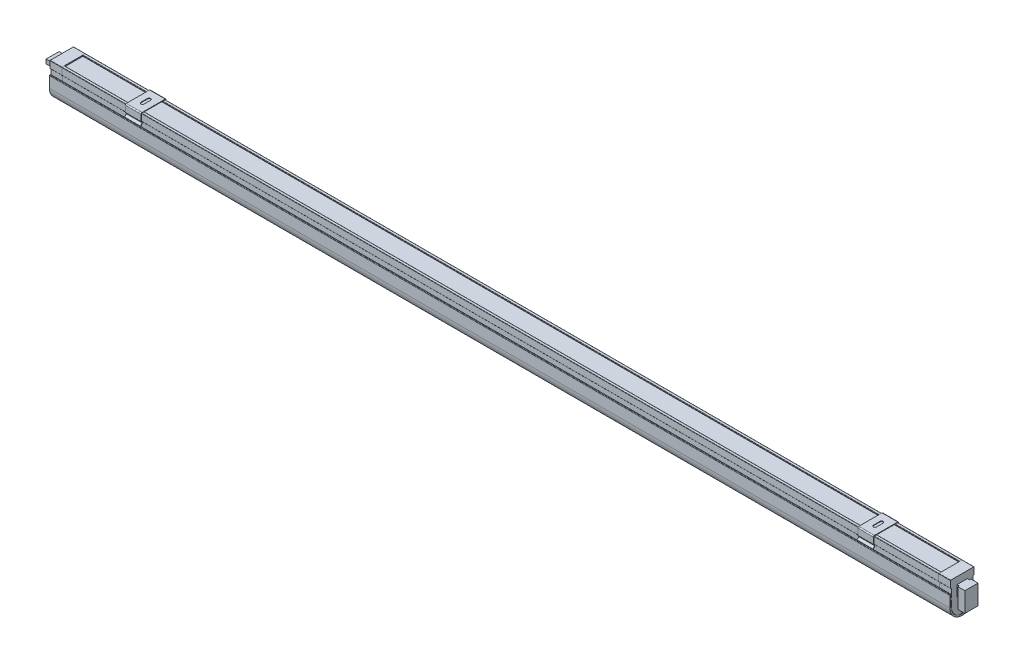
from build123d import *

# Parameters (mm, degrees)
BOSS_EXTRUDE1_DEPTH    = 848.36
BOSS_EXTRUDE2_DEPTH    = 848.36
BOSS_EXTRUDE3_DEPTH    = 11.43
CUT_EXTRUDE2_DEPTH     = 10.0076
BOSS_EXTRUDE6_REACH    = 13.43
BOSS_EXTRUDE7_DEPTH    = 6.7818
SKETCH5_4_W            = 10.16
SKETCH5_4_H            = 10.16
BOSS_EXTRUDE9_DEPTH    = 8.89
SKETCH6_W              = 12.7
SKETCH6_H              = 3.9878
BOSS_EXTRUDE10_DEPTH   = 8.89
SKETCH7_R              = 2.54
CUT_EXTRUDE3_DEPTH     = 6.096
SKETCH8_R              = 2.2606
SKETCH8_R_2            = 1.143
BOSS_EXTRUDE11_DEPTH   = 5.842
SKETCH8_2_R            = 1.143
BOSS_EXTRUDE12_DEPTH   = 13.7922
FILLET1_R              = 1.1176
BOSS_EXTRUDE13_START   = 424.18
SKETCH9_R              = 1.143
BOSS_EXTRUDE13_DEPTH   = 6.985
BOSS_EXTRUDE13_2_DEPTH = 6.985
BOSS_EXTRUDE14_START   = 424.18
SKETCH9_4_R            = 1.143
BOSS_EXTRUDE14_DEPTH   = 2.032
BOSS_EXTRUDE15_START   = 413.1818
SKETCH9_5_R            = 7.62
SKETCH9_5_R_2          = 7.3025
SKETCH9_5_R_3          = 1.143
BOSS_EXTRUDE15_DEPTH   = 8.9662
SKETCH9_6_R            = 7.9375
SKETCH9_6_R_2          = 7.62
SKETCH9_6_R_3          = 7.3025
BOSS_EXTRUDE16_DEPTH   = 413.1818
FILLET3_R              = 0.127
BOSS_EXTRUDE17_DEPTH   = 871.22
BOSS_EXTRUDE18_START   = -82.55
BOSS_EXTRUDE18_DEPTH   = 15.24
CUT_EXTRUDE4_DEPTH     = 0.508


with BuildPart() as part:
    # Sketch1 → Boss-Extrude1 (new body)
    with BuildSketch(Plane(origin=(-20.32, 0, 0), x_dir=(0, 0, -1), z_dir=(1, 0, 0))):
        with BuildLine():
            Line((2.3114, 0), (0.254, 0))
            ThreePointArc((0.254, 0), (0.074394878, -0.074394878), (0, -0.254))
            Line((0, -0.254), (0, -6.540681466))
            ThreePointArc((0, -6.540681466), (0.134713703, -6.859448936), (0.4572, -6.985))
            ThreePointArc((0.4572, -6.985), (0.779686297, -7.110551064), (0.9144, -7.429318534))
            Line((0.9144, -7.429318534), (0.9144, -14.986207389))
            ThreePointArc((0.9144, -14.986207389), (0.760441483, -15.350513069), (0.391885714, -15.494))
            ThreePointArc((0.391885714, -15.494), (0.115468888, -15.601615198), (0, -15.874844458))
            Line((0, -15.874844458), (0, -16.383362931))
            ThreePointArc((0, -16.383362931), (0.115468888, -16.656592191), (0.391885714, -16.764207389))
            ThreePointArc((0.391885714, -16.764207389), (0.760441483, -16.90769432), (0.9144, -17.272))
            ThreePointArc((0.9144, -17.272), (1.937798719, -19.036014585), (3.97714356, -19.023168671))
            ThreePointArc((3.97714356, -19.023168671), (7.567737766, -17.509328725), (11.43, -16.9926))
            ThreePointArc((11.43, -16.9926), (15.292262234, -17.509328725), (18.88285644, -19.023168671))
            ThreePointArc((18.88285644, -19.023168671), (20.922201281, -19.036014585), (21.9456, -17.272))
            ThreePointArc((21.9456, -17.272), (22.099558517, -16.90769432), (22.468114286, -16.764207389))
            ThreePointArc((22.468114286, -16.764207389), (22.744531112, -16.656592191), (22.86, -16.383362931))
            Line((22.86, -16.383362931), (22.86, -15.874844458))
            ThreePointArc((22.86, -15.874844458), (22.744531112, -15.601615198), (22.468114286, -15.494))
            ThreePointArc((22.468114286, -15.494), (22.099558517, -15.350513069), (21.9456, -14.986207389))
            Line((21.9456, -14.986207389), (21.9456, -7.429318534))
            ThreePointArc((21.9456, -7.429318534), (22.080313703, -7.110551064), (22.4028, -6.985))
            ThreePointArc((22.4028, -6.985), (22.725286297, -6.859448936), (22.86, -6.540681466))
            Line((22.86, -6.540681466), (22.86, -0.254))
            ThreePointArc((22.86, -0.254), (22.785605122, -0.074394878), (22.606, 0))
            Line((22.606, 0), (20.5486, 0))
            ThreePointArc((20.5486, 0), (20.368994878, -0.074394878), (20.2946, -0.254))
            Line((20.2946, -0.254), (20.2946, -0.762))
            ThreePointArc((20.2946, -0.762), (20.368994878, -0.941605122), (20.5486, -1.016))
            Line((20.5486, -1.016), (21.59, -1.016))
            Line((21.59, -1.016), (21.59, -1.524))
            Line((21.59, -1.524), (21.1836, -1.524))
            Line((21.1836, -1.524), (21.1836, -17.272))
            ThreePointArc((21.1836, -17.272), (20.5439758, -18.374509116), (19.269385275, -18.366480419))
            ThreePointArc((19.269385275, -18.366480419), (15.492571435, -16.77412792), (11.43, -16.2306))
            ThreePointArc((11.43, -16.2306), (7.367428565, -16.77412792), (3.590614725, -18.366480419))
            ThreePointArc((3.590614725, -18.366480419), (2.3160242, -18.374509116), (1.6764, -17.272))
            Line((1.6764, -17.272), (1.6764, -1.524))
            Line((1.6764, -1.524), (1.27, -1.524))
            Line((1.27, -1.524), (1.27, -1.016))
            Line((1.27, -1.016), (2.3114, -1.016))
            ThreePointArc((2.3114, -1.016), (2.491005122, -0.941605122), (2.5654, -0.762))
            Line((2.5654, -0.762), (2.5654, -0.254))
            ThreePointArc((2.5654, -0.254), (2.491005122, -0.074394878), (2.3114, 0))
        make_face()
    extrude(amount=-BOSS_EXTRUDE1_DEPTH)


with BuildPart() as body_2:
    # Sketch1_3 → Boss-Extrude2 (new body)
    with BuildSketch(Plane(origin=(-20.32, 0, 0), x_dir=(0, 0, -1), z_dir=(1, 0, 0))):
        Polygon((11.43, -1.524), (1.27, -1.524), (1.27, -1.016), (11.43, -1.016), (21.59, -1.016), (21.59, -1.524), align=None)
    extrude(amount=-BOSS_EXTRUDE2_DEPTH)


with BuildPart() as body_3:
    # Sketch3 → Boss-Extrude3 (new body)
    with BuildSketch(Plane(origin=(-20.32, 0, 0), x_dir=(0, 0, -1), z_dir=(1, 0, 0))):
        with BuildLine():
            Line((0, -6.540681466), (0, -0.254))
            ThreePointArc((0, -0.254), (0.074394878, -0.074394878), (0.254, 0))
            Line((0.254, 0), (22.606, 0))
            ThreePointArc((22.606, 0), (22.785605122, -0.074394878), (22.86, -0.254))
            Line((22.86, -0.254), (22.86, -6.540681466))
            ThreePointArc((22.86, -6.540681466), (22.725286297, -6.859448936), (22.4028, -6.985))
            ThreePointArc((22.4028, -6.985), (22.080313703, -7.110551064), (21.9456, -7.429318534))
            Line((21.9456, -7.429318534), (21.9456, -14.986207389))
            ThreePointArc((21.9456, -14.986207389), (22.099558517, -15.350513069), (22.468114286, -15.494))
            ThreePointArc((22.468114286, -15.494), (22.744531112, -15.601615198), (22.86, -15.874844458))
            Line((22.86, -15.874844458), (22.86, -16.383362931))
            ThreePointArc((22.86, -16.383362931), (22.744531112, -16.656592191), (22.468114286, -16.764207389))
            ThreePointArc((22.468114286, -16.764207389), (22.099558517, -16.90769432), (21.9456, -17.272))
            Line((21.9456, -17.272), (21.9456, -23.0124))
            ThreePointArc((21.9456, -23.0124), (19.407197451, -29.863835191), (13.0175, -33.407479947))
            Line((13.0175, -33.407479947), (13.0175, -33.02))
            Line((13.0175, -33.02), (9.8425, -33.02))
            Line((9.8425, -33.02), (9.8425, -33.407479947))
            ThreePointArc((9.8425, -33.407479947), (3.452802549, -29.863835191), (0.9144, -23.0124))
            Line((0.9144, -23.0124), (0.9144, -17.272))
            ThreePointArc((0.9144, -17.272), (0.760441483, -16.90769432), (0.391885714, -16.764207389))
            ThreePointArc((0.391885714, -16.764207389), (0.115468888, -16.656592191), (0, -16.383362931))
            Line((0, -16.383362931), (0, -15.874844458))
            ThreePointArc((0, -15.874844458), (0.115468888, -15.601615198), (0.391885714, -15.494))
            ThreePointArc((0.391885714, -15.494), (0.760441483, -15.350513069), (0.9144, -14.986207389))
            Line((0.9144, -14.986207389), (0.9144, -7.429318534))
            ThreePointArc((0.9144, -7.429318534), (0.779686297, -7.110551064), (0.4572, -6.985))
            ThreePointArc((0.4572, -6.985), (0.134713703, -6.859448936), (0, -6.540681466))
        make_face()
    extrude(amount=BOSS_EXTRUDE3_DEPTH)

    # Sketch4 → Cut-Extrude2 (cut)
    with BuildSketch(Plane.ZY.offset(20.32)):
        with BuildLine():
            Line((-13.0175, -32.859367617), (-13.0175, -33.02))
            Line((-13.0175, -33.02), (-9.8425, -33.02))
            Line((-9.8425, -33.02), (-9.8425, -32.859367617))
            ThreePointArc((-9.8425, -32.859367617), (-11.43, -17.1704), (-13.0175, -32.859367617))
        make_face()
    extrude(amount=-CUT_EXTRUDE2_DEPTH, mode=Mode.SUBTRACT)


with BuildPart() as body_4:

    # Sketch4_6 → Boss-Extrude6 (new, up to next)
    with BuildSketch(Plane.ZY.offset(20.32), mode=Mode.PRIVATE) as boss_extrude6_sk1:
        with BuildLine():
            Line((-9.8425, -18.7452), (-9.8425, -32.223057322))
            ThreePointArc((-9.8425, -32.223057322), (-5.732666194, -29.663229526), (-4.1275, -25.0952))
            ThreePointArc((-4.1275, -25.0952), (-5.732666194, -20.527170474), (-9.8425, -17.967342678))
            Line((-9.8425, -17.967342678), (-9.8425, -18.7452))
        make_face()
    boss_extrude6_tool1 = extrude(boss_extrude6_sk1.sketch, amount=-BOSS_EXTRUDE6_REACH, mode=Mode.PRIVATE) - body_3.part
    # Sketch4_6 → Boss-Extrude6 (new, up to next)
    with BuildSketch(Plane.ZY.offset(20.32), mode=Mode.PRIVATE) as boss_extrude6_sk2:
        with BuildLine():
            ThreePointArc((-13.0175, -17.967342678), (-18.7325, -25.0952), (-13.0175, -32.223057322))
            Line((-13.0175, -32.223057322), (-13.0175, -18.7452))
            Line((-13.0175, -18.7452), (-13.0175, -17.967342678))
        make_face()
    boss_extrude6_tool2 = extrude(boss_extrude6_sk2.sketch, amount=-BOSS_EXTRUDE6_REACH, mode=Mode.PRIVATE) - body_3.part
    # Sketch4_6 → Boss-Extrude6 (new, up to next)
    with BuildSketch(Plane.ZY.offset(20.32), mode=Mode.PRIVATE) as boss_extrude6_sk3:
        with BuildLine():
            Line((-13.0175, -17.967342678), (-13.0175, -18.7452))
            ThreePointArc((-13.0175, -18.7452), (-11.43, -18.549695074), (-9.8425, -18.7452))
            Line((-9.8425, -18.7452), (-9.8425, -17.967342678))
            ThreePointArc((-9.8425, -17.967342678), (-11.43, -17.7927), (-13.0175, -17.967342678))
        make_face()
    boss_extrude6_tool3 = extrude(boss_extrude6_sk3.sketch, amount=-BOSS_EXTRUDE6_REACH, mode=Mode.PRIVATE) - body_3.part
    add(boss_extrude6_tool1.solids().sort_by_distance((-20.32, -25.0952, -7.456782))[0])
    add(boss_extrude6_tool2.solids().sort_by_distance((-20.32, -25.0952, -15.403218))[0])
    add(boss_extrude6_tool3.solids().sort_by_distance((-20.32, -18.232997, -11.43))[0])


with BuildPart() as body_5:
    # Mirror1: mirrored copy
    add(body_3.part.mirror(Plane(origin=(-444.5, 0, 0), x_dir=(0, 0, 1), z_dir=(1, 0, 0))))


with BuildPart() as body_6:
    # Mirror1 2: mirrored copy
    add(body_4.part.mirror(Plane(origin=(-444.5, 0, 0), x_dir=(0, 0, 1), z_dir=(1, 0, 0))))


with BuildPart() as body_7:
    # Sketch5 → Boss-Extrude7 (new body)
    with BuildSketch(Plane(origin=(0, 0, 0), x_dir=(0, 0, -1), z_dir=(1, 0, 0))):
        Polygon((6.35, -6.7818), (5.08, -6.7818), (5.08, -25.8318), (17.78, -25.8318), (17.78, -6.7818), (16.51, -6.7818), (16.51, -16.9418), (6.35, -16.9418), align=None)
    extrude(amount=-BOSS_EXTRUDE7_DEPTH)

    # Sketch5_4 → Boss-Extrude9 (add)
    with BuildSketch(Plane(origin=(0, 0, 0), x_dir=(0, 0, -1), z_dir=(1, 0, 0))):
        with Locations((11.43, -11.8618)):
            Rectangle(SKETCH5_4_W, SKETCH5_4_H)
    extrude(amount=-BOSS_EXTRUDE9_DEPTH)

    # Sketch7 → Cut-Extrude3 (cut)
    with BuildSketch(Plane.XZ.offset(25.8318)):
        with Locations(Location((-3.3909, -8.509, 0), (0, 0, 270))):
            Circle(SKETCH7_R)
        with Locations(Location((-3.3909, -14.351, 0), (0, 0, 270))):
            Circle(SKETCH7_R)
    extrude(amount=-CUT_EXTRUDE3_DEPTH, mode=Mode.SUBTRACT)


with BuildPart() as body_8:
    # Sketch6 → Boss-Extrude10 (new body)
    with BuildSketch(Plane(origin=(-889, 0, 0), x_dir=(0, 0, -1), z_dir=(1, 0, 0))):
        with Locations((11.43, -7.8867)):
            Rectangle(SKETCH6_W, SKETCH6_H)
    extrude(amount=BOSS_EXTRUDE10_DEPTH)

    # Sketch8 → Boss-Extrude11 (add)
    with BuildSketch(Plane.XZ.offset(9.8806)):
        with Locations(Location((-884.555, -8.4836, 0), (0, 0, 90))):
            Circle(SKETCH8_R)
        with Locations(Location((-884.555, -8.4836, 0), (0, 0, 270))):
            Circle(SKETCH8_R_2, mode=Mode.SUBTRACT)
        with Locations(Location((-884.555, -14.3764, 0), (0, 0, 90))):
            Circle(SKETCH8_R)
        with Locations(Location((-884.555, -14.3764, 0), (0, 0, 270))):
            Circle(SKETCH8_R_2, mode=Mode.SUBTRACT)
    extrude(amount=BOSS_EXTRUDE11_DEPTH)

    # Sketch8_2 → Boss-Extrude12 (add)
    with BuildSketch(Plane.XZ.offset(9.8806)):
        with Locations(Location((-884.555, -8.4836, 0), (0, 0, 90))):
            Circle(SKETCH8_2_R)
        with Locations(Location((-884.555, -14.3764, 0), (0, 0, 90))):
            Circle(SKETCH8_2_R)
    extrude(amount=BOSS_EXTRUDE12_DEPTH)

    # Fillet1
    fillet1_edges = [body_8.edges().sort_by_distance(p)[0] for p in [
        (-884.555, -23.6728, -9.6266),
        (-884.555, -23.6728, -15.5194),
    ]]
    fillet(fillet1_edges, radius=FILLET1_R)


with BuildPart() as body_9:
    # Sketch9 → Boss-Extrude13 (new body)
    with BuildSketch(Plane(origin=(-444.5, 0, 0), x_dir=(0, 0, -1), z_dir=(1, 0, 0)).offset(BOSS_EXTRUDE13_START)):
        with Locations((11.43, -22.717797537)):
            Circle(SKETCH9_R)
    extrude(amount=BOSS_EXTRUDE13_DEPTH)



with BuildPart() as body_10:
    # Sketch9 → Boss-Extrude13 2 (new body)
    with BuildSketch(Plane(origin=(-444.5, 0, 0), x_dir=(0, 0, -1), z_dir=(1, 0, 0)).offset(BOSS_EXTRUDE13_START)):
        with Locations((11.43, -27.467597537)):
            Circle(SKETCH9_R)
    extrude(amount=BOSS_EXTRUDE13_2_DEPTH)


with BuildPart() as body_9_1:
    add(body_9.part)

    add(body_10.part)  # Boss-Extrude14 merges body 10
    # Sketch9_4 → Boss-Extrude14 (add)
    with BuildSketch(Plane(origin=(-444.5, 0, 0), x_dir=(0, 0, -1), z_dir=(1, 0, 0)).offset(BOSS_EXTRUDE14_START)):
        with BuildLine():
            ThreePointArc((16.8656, -20.21614559), (11.43, -17.790197537), (5.9944, -20.21614559))
            Line((5.9944, -20.21614559), (5.9944, -29.969249484))
            ThreePointArc((5.9944, -29.969249484), (11.43, -32.395197537), (16.8656, -29.969249484))
            Line((16.8656, -29.969249484), (16.8656, -20.21614559))
        make_face()
        with Locations((11.43, -27.467597537)):
            Circle(SKETCH9_4_R, mode=Mode.SUBTRACT)
        with Locations((11.43, -22.717797537)):
            Circle(SKETCH9_4_R, mode=Mode.SUBTRACT)
        with Locations((11.43, -22.717797537)):
            Circle(SKETCH9_4_R)
        with Locations((11.43, -27.467597537)):
            Circle(SKETCH9_4_R)
    extrude(amount=-BOSS_EXTRUDE14_DEPTH)

    # Sketch9_5 → Boss-Extrude15 (add)
    with BuildSketch(Plane(origin=(-444.5, 0, 0), x_dir=(0, 0, -1), z_dir=(1, 0, 0)).offset(BOSS_EXTRUDE15_START)):
        with Locations((11.43, -25.092697537)):
            Circle(SKETCH9_5_R)
        with Locations((11.43, -25.092697537)):
            Circle(SKETCH9_5_R_2, mode=Mode.SUBTRACT)
        with BuildLine():
            Line((5.9944, -29.969249484), (5.9944, -20.21614559))
            ThreePointArc((5.9944, -20.21614559), (4.1275, -25.092697537), (5.9944, -29.969249484))
        make_face()
        with BuildLine():
            ThreePointArc((16.8656, -20.21614559), (11.43, -17.790197537), (5.9944, -20.21614559))
            Line((5.9944, -20.21614559), (5.9944, -29.969249484))
            ThreePointArc((5.9944, -29.969249484), (11.43, -32.395197537), (16.8656, -29.969249484))
            Line((16.8656, -29.969249484), (16.8656, -20.21614559))
        make_face()
        with Locations((11.43, -27.467597537)):
            Circle(SKETCH9_5_R_3, mode=Mode.SUBTRACT)
        with Locations((11.43, -22.717797537)):
            Circle(SKETCH9_5_R_3, mode=Mode.SUBTRACT)
        with Locations((11.43, -22.717797537)):
            Circle(SKETCH9_5_R_3)
        with Locations((11.43, -27.467597537)):
            Circle(SKETCH9_5_R_3)
        with BuildLine():
            ThreePointArc((18.7325, -25.092697537), (18.249823137, -22.481851194), (16.8656, -20.21614559))
            Line((16.8656, -20.21614559), (16.8656, -29.969249484))
            ThreePointArc((16.8656, -29.969249484), (18.249823137, -27.70354388), (18.7325, -25.092697537))
        make_face()
    extrude(amount=BOSS_EXTRUDE15_DEPTH)

    # Sketch9_6 → Boss-Extrude16 (add)
    with BuildSketch(Plane(origin=(-444.5, 0, 0), x_dir=(0, 0, -1), z_dir=(1, 0, 0))):
        with Locations((11.43, -25.092697537)):
            Circle(SKETCH9_6_R)
        with Locations((11.43, -25.092697537)):
            Circle(SKETCH9_6_R_2, mode=Mode.SUBTRACT)
        with Locations((11.43, -25.092697537)):
            Circle(SKETCH9_6_R_2)
        with Locations((11.43, -25.092697537)):
            Circle(SKETCH9_6_R_3, mode=Mode.SUBTRACT)
    extrude(amount=BOSS_EXTRUDE16_DEPTH)

    # Fillet3
    fillet3_edges = [body_9_1.edges().sort_by_distance(p)[0] for p in [
        (-31.3182, -25.092697537, -3.81),
        (-31.3182, -25.092697537, -3.4925),
    ]]
    fillet(fillet3_edges, radius=FILLET3_R)

    # Mirror2: body 9 across plane


with BuildPart() as body_9_2:
    add(body_9_1.part)
    add(body_9_1.part.mirror(Plane(origin=(-444.5, 0, 0), x_dir=(0, 0, 1), z_dir=(1, 0, 0))))


with BuildPart() as body_10_2:
    # Sketch10 → Boss-Extrude17 (new body)
    with BuildSketch(Plane(origin=(-8.89, 0, 0), x_dir=(0, 0, -1), z_dir=(1, 0, 0))):
        with BuildLine():
            ThreePointArc((0.7874, -12.438237222), (0.657208964, -12.123928258), (0.3429, -11.993737222))
            Line((0.3429, -11.993737222), (-0.1651, -11.993737222))
            ThreePointArc((-0.1651, -11.993737222), (-0.479408964, -12.123928258), (-0.6096, -12.438237222))
            Line((-0.6096, -12.438237222), (-0.6096, -23.0124))
            ThreePointArc((-0.6096, -23.0124), (2.911309562, -31.566470345), (11.43, -35.172137665))
            ThreePointArc((11.43, -35.172137665), (19.948690438, -31.566470345), (23.4696, -23.0124))
            Line((23.4696, -23.0124), (23.4696, -12.438237222))
            ThreePointArc((23.4696, -12.438237222), (23.339408964, -12.123928258), (23.0251, -11.993737222))
            Line((23.0251, -11.993737222), (22.5171, -11.993737222))
            ThreePointArc((22.5171, -11.993737222), (22.202791036, -12.123928258), (22.0726, -12.438237222))
            Line((22.0726, -12.438237222), (22.0726, -14.863937222))
            ThreePointArc((22.0726, -14.863937222), (22.203857117, -15.204713982), (22.5298, -15.36939084))
            ThreePointArc((22.5298, -15.36939084), (22.855742883, -15.534067698), (22.987, -15.874844458))
            Line((22.987, -15.874844458), (22.987, -16.36241244))
            ThreePointArc((22.987, -16.36241244), (22.855742883, -16.7031892), (22.5298, -16.867866058))
            ThreePointArc((22.5298, -16.867866058), (22.203857117, -17.032542916), (22.0726, -17.373319676))
            Line((22.0726, -17.373319676), (22.0726, -23.0124))
            ThreePointArc((22.0726, -23.0124), (21.949624429, -23.21849213), (22.064254778, -23.429340038))
            ThreePointArc((22.064254778, -23.429340038), (22.064111918, -23.432950945), (22.063967846, -23.436561803))
            ThreePointArc((22.063967846, -23.436561803), (21.933255244, -23.637507313), (22.039233102, -23.852527256))
            ThreePointArc((22.039233102, -23.852527256), (22.038935889, -23.856285642), (22.038637359, -23.860043924))
            ThreePointArc((22.038637359, -23.860043924), (21.900401415, -24.055553365), (21.997577296, -24.274391128))
            ThreePointArc((21.997577296, -24.274391128), (21.997113921, -24.278290188), (21.996649124, -24.282189079))
            ThreePointArc((21.996649124, -24.282189079), (21.851113862, -24.471982008), (21.939353124, -24.694278435))
            ThreePointArc((21.939353124, -24.694278435), (21.938712126, -24.69831042), (21.938069599, -24.702342162))
            ThreePointArc((21.938069599, -24.702342162), (21.785468988, -24.886147469), (21.864651967, -25.111539114))
            ThreePointArc((21.864651967, -25.111539114), (21.863822304, -25.11569535), (21.862991005, -25.11985126))
            ThreePointArc((21.862991005, -25.11985126), (21.703568564, -25.297407482), (21.773590665, -25.525527258))
            ThreePointArc((21.773590665, -25.525527258), (21.772561791, -25.529798173), (21.771531175, -25.534068668))
            ThreePointArc((21.771531175, -25.534068668), (21.605539568, -25.705124285), (21.666311336, -25.935602115))
            ThreePointArc((21.666311336, -25.935602115), (21.665073272, -25.939977268), (21.663833361, -25.944351897))
            ThreePointArc((21.663833361, -25.944351897), (21.491533991, -26.108665609), (21.542981144, -26.341129067))
            ThreePointArc((21.542981144, -26.341129067), (21.54152455, -26.345597185), (21.540066006, -26.350064667))
            ThreePointArc((21.540066006, -26.350064667), (21.3617286, -26.507405657), (21.403792041, -26.741480612))
            ThreePointArc((21.403792041, -26.741480612), (21.402108281, -26.746029635), (21.400422473, -26.750577899))
            ThreePointArc((21.400422473, -26.750577899), (21.216324664, -26.900726076), (21.248960456, -27.136037324))
            ThreePointArc((21.248960456, -27.136037324), (21.247041667, -27.140654451), (21.245120735, -27.145270686))
            ThreePointArc((21.245120735, -27.145270686), (21.055547642, -27.288016915), (21.078726967, -27.524188806))
            ThreePointArc((21.078726967, -27.524188806), (21.076566115, -27.52886055), (21.074403031, -27.53353126))
            ThreePointArc((21.074403031, -27.53353126), (20.879646837, -27.668677574), (20.893355912, -27.90533463))
            ThreePointArc((20.893355912, -27.90533463), (20.890946854, -27.910046875), (20.888535481, -27.914757936))
            ThreePointArc((20.888535481, -27.914757936), (20.688895003, -28.04211773), (20.693134986, -28.278885254))
            ThreePointArc((20.693134986, -28.278885254), (20.69047252, -28.283623319), (20.687807664, -28.288360041))
            ThreePointArc((20.687807664, -28.288360041), (20.483587927, -28.407758258), (20.478374792, -28.644262926))
            ThreePointArc((20.478374792, -28.644262926), (20.475454705, -28.649011636), (20.472532161, -28.653758834))
            ThreePointArc((20.472532161, -28.653758834), (20.264043969, -28.765032125), (20.249408354, -29.000902577))
            ThreePointArc((20.249408354, -29.000902577), (20.246227467, -29.005646328), (20.243044064, -29.010388393))
            ThreePointArc((20.243044064, -29.010388393), (20.030603569, -29.113385272), (20.006590604, -29.348252678))
            ThreePointArc((20.006590604, -29.348252678), (20.003146807, -29.35297552), (19.999700447, -29.357696492))
            ThreePointArc((19.999700447, -29.357696492), (19.783628717, -29.452277473), (19.750297833, -29.685776095))
            ThreePointArc((19.750297833, -29.685776095), (19.746590117, -29.690461804), (19.742879802, -29.695145455))
            ThreePointArc((19.742879802, -29.695145455), (19.523502395, -29.781183172), (19.480927107, -30.012950902))
            ThreePointArc((19.480927107, -30.012950902), (19.476955591, -30.017583066), (19.472981452, -30.022212978))
            ThreePointArc((19.472981452, -30.022212978), (19.250627981, -30.0995923), (19.198895656, -30.32927119))
            ThreePointArc((19.198895656, -30.32927119), (19.194661605, -30.333833289), (19.190424918, -30.338392941))
            ThreePointArc((19.190424918, -30.338392941), (18.965428623, -30.407011063), (18.904640229, -30.634247836))
            ThreePointArc((18.904640229, -30.634247836), (18.900146065, -30.638723332), (18.895649266, -30.64319618))
            ThreePointArc((18.895649266, -30.64319618), (18.668346585, -30.702962712), (18.598616418, -30.927409255))
            ThreePointArc((18.598616418, -30.927409255), (18.593865729, -30.931781673), (18.589112419, -30.936151242))
            ThreePointArc((18.589112419, -30.936151242), (18.359842559, -30.986988277), (18.281297963, -31.208302124))
            ThreePointArc((18.281297963, -31.208302124), (18.276295499, -31.212555143), (18.271290442, -31.216805112))
            ThreePointArc((18.271290442, -31.216805112), (18.040394954, -31.258647285), (17.953176016, -31.476492071))
            ThreePointArc((17.953176016, -31.476492071), (17.947927683, -31.480609611), (17.942676801, -31.484723899))
            ThreePointArc((17.942676801, -31.484723899), (17.710499148, -31.517518439), (17.614758389, -31.731564348))
            ThreePointArc((17.614758389, -31.731564348), (17.609271234, -31.735530655), (17.603781587, -31.739493512))
            ThreePointArc((17.603781587, -31.739493512), (17.370666727, -31.763200275), (17.266568773, -31.973124463))
            ThreePointArc((17.266568773, -31.973124463), (17.260850962, -31.976924196), (17.255130731, -31.980720283))
            ThreePointArc((17.255130731, -31.980720283), (17.021424686, -31.99531178), (16.90914593, -32.200798783))
            ThreePointArc((16.90914593, -32.200798783), (16.903206721, -32.204417099), (16.897265178, -32.208031579))
            ThreePointArc((16.897265178, -32.208031579), (16.663314613, -32.213492986), (16.543042871, -32.414235113))
            ThreePointArc((16.543042871, -32.414235113), (16.536892577, -32.417657747), (16.530740048, -32.421076362))
            ThreePointArc((16.530740048, -32.421076362), (16.296891853, -32.417405529), (16.168826001, -32.613103232))
            ThreePointArc((16.168826001, -32.613103232), (16.162475949, -32.61631658), (16.156123776, -32.619525731))
            ThreePointArc((16.156123776, -32.619525731), (15.922724641, -32.606733174), (15.787074253, -32.797095402))
            ThreePointArc((15.787074253, -32.797095402), (15.780536738, -32.800086593), (15.773997227, -32.803073419))
            ThreePointArc((15.773997227, -32.803073419), (15.541393225, -32.781182301), (15.398378198, -32.965926841))
            ThreePointArc((15.398378198, -32.965926841), (15.391666425, -32.968683813), (15.384952797, -32.971436263))
            ThreePointArc((15.384952797, -32.971436263), (15.153488963, -32.940482368), (15.003339137, -33.119336162))
            ThreePointArc((15.003339137, -33.119336162), (14.996467167, -33.121847729), (14.989593493, -33.124354627))
            ThreePointArc((14.989593493, -33.124354627), (14.759613408, -33.084386322), (14.602568181, -33.257085775))
            ThreePointArc((14.602568181, -33.257085775), (14.595550862, -33.25934169), (14.588532001, -33.261592802))
            ThreePointArc((14.588532001, -33.261592802), (14.360377375, -33.212670991), (14.19668531, -33.378962255))
            ThreePointArc((14.19668531, -33.378962255), (14.189538209, -33.380953269), (14.182389738, -33.38293936))
            ThreePointArc((14.182389738, -33.38293936), (13.956399992, -33.325137423), (13.786318423, -33.484776668))
            ThreePointArc((13.786318423, -33.484776668), (13.77905775, -33.486494586), (13.771795889, -33.488207473))
            ThreePointArc((13.771795889, -33.488207473), (13.548307741, -33.4216112), (13.372102374, -33.574364872))
            ThreePointArc((13.372102374, -33.574364872), (13.364744906, -33.575802594), (13.357386439, -33.577235193))
            ThreePointArc((13.357386439, -33.577235193), (13.136733487, -33.501942704), (12.954677996, -33.647587762))
            ThreePointArc((12.954677996, -33.647587762), (12.947240993, -33.648739329), (12.939803187, -33.649885699))
            ThreePointArc((12.939803187, -33.649885699), (12.722315493, -33.566007353), (12.53469112, -33.704331496))
            ThreePointArc((12.53469112, -33.704331496), (12.527192239, -33.705192123), (12.519692757, -33.706047495))
            ThreePointArc((12.519692757, -33.706047495), (12.305696437, -33.613705791), (12.112791578, -33.744507668))
            ThreePointArc((12.112791578, -33.744507668), (12.105248788, -33.745073773), (12.097705602, -33.74563458))
            ThreePointArc((12.097705602, -33.74563458), (11.887522406, -33.644964045), (11.689632208, -33.768053451))
            ThreePointArc((11.689632208, -33.768053451), (11.682063697, -33.768322672), (11.674495, -33.768586571))
            ThreePointArc((11.674495, -33.768586571), (11.567977912, -33.679430766), (11.43, -33.663407546))
            ThreePointArc((11.43, -33.663407546), (11.292022088, -33.679430766), (11.185505, -33.768586571))
            ThreePointArc((11.185505, -33.768586571), (11.177936303, -33.768322672), (11.170367792, -33.768053451))
            ThreePointArc((11.170367792, -33.768053451), (10.972477594, -33.644964045), (10.762294398, -33.74563458))
            ThreePointArc((10.762294398, -33.74563458), (10.754751212, -33.745073773), (10.747208422, -33.744507668))
            ThreePointArc((10.747208422, -33.744507668), (10.554303563, -33.613705791), (10.340307243, -33.706047495))
            ThreePointArc((10.340307243, -33.706047495), (10.332807761, -33.705192123), (10.32530888, -33.704331496))
            ThreePointArc((10.32530888, -33.704331496), (10.137684507, -33.566007353), (9.920196813, -33.649885699))
            ThreePointArc((9.920196813, -33.649885699), (9.912759007, -33.648739329), (9.905322004, -33.647587762))
            ThreePointArc((9.905322004, -33.647587762), (9.723266513, -33.501942704), (9.502613561, -33.577235193))
            ThreePointArc((9.502613561, -33.577235193), (9.495255094, -33.575802594), (9.487897626, -33.574364872))
            ThreePointArc((9.487897626, -33.574364872), (9.311692259, -33.4216112), (9.088204111, -33.488207473))
            ThreePointArc((9.088204111, -33.488207473), (9.08094225, -33.486494586), (9.073681577, -33.484776668))
            ThreePointArc((9.073681577, -33.484776668), (8.903600008, -33.325137423), (8.677610262, -33.38293936))
            ThreePointArc((8.677610262, -33.38293936), (8.670461791, -33.380953269), (8.66331469, -33.378962255))
            ThreePointArc((8.66331469, -33.378962255), (8.499622625, -33.212670991), (8.271467999, -33.261592802))
            ThreePointArc((8.271467999, -33.261592802), (8.264449138, -33.25934169), (8.257431819, -33.257085775))
            ThreePointArc((8.257431819, -33.257085775), (8.100386592, -33.084386322), (7.870406507, -33.124354627))
            ThreePointArc((7.870406507, -33.124354627), (7.863532833, -33.121847729), (7.856660863, -33.119336162))
            ThreePointArc((7.856660863, -33.119336162), (7.706511037, -32.940482368), (7.475047203, -32.971436263))
            ThreePointArc((7.475047203, -32.971436263), (7.468333575, -32.968683813), (7.461621802, -32.965926841))
            ThreePointArc((7.461621802, -32.965926841), (7.318606775, -32.781182301), (7.086002773, -32.803073419))
            ThreePointArc((7.086002773, -32.803073419), (7.079463262, -32.800086593), (7.072925747, -32.797095402))
            ThreePointArc((7.072925747, -32.797095402), (6.937275359, -32.606733174), (6.703876224, -32.619525731))
            ThreePointArc((6.703876224, -32.619525731), (6.697524051, -32.61631658), (6.691173999, -32.613103232))
            ThreePointArc((6.691173999, -32.613103232), (6.563108147, -32.417405529), (6.329259952, -32.421076362))
            ThreePointArc((6.329259952, -32.421076362), (6.323107423, -32.417657747), (6.316957129, -32.414235113))
            ThreePointArc((6.316957129, -32.414235113), (6.196685387, -32.213492986), (5.962734822, -32.208031579))
            ThreePointArc((5.962734822, -32.208031579), (5.956793279, -32.204417099), (5.95085407, -32.200798783))
            ThreePointArc((5.95085407, -32.200798783), (5.838575314, -31.99531178), (5.604869269, -31.980720283))
            ThreePointArc((5.604869269, -31.980720283), (5.599149038, -31.976924196), (5.593431227, -31.973124463))
            ThreePointArc((5.593431227, -31.973124463), (5.489333273, -31.763200275), (5.256218413, -31.739493512))
            ThreePointArc((5.256218413, -31.739493512), (5.250728766, -31.735530655), (5.245241611, -31.731564348))
            ThreePointArc((5.245241611, -31.731564348), (5.149500852, -31.517518439), (4.917323199, -31.484723899))
            ThreePointArc((4.917323199, -31.484723899), (4.912072317, -31.480609611), (4.906823984, -31.476492071))
            ThreePointArc((4.906823984, -31.476492071), (4.819605046, -31.258647285), (4.588709558, -31.216805112))
            ThreePointArc((4.588709558, -31.216805112), (4.583704501, -31.212555143), (4.578702037, -31.208302124))
            ThreePointArc((4.578702037, -31.208302124), (4.500157441, -30.986988277), (4.270887581, -30.936151242))
            ThreePointArc((4.270887581, -30.936151242), (4.266134271, -30.931781673), (4.261383582, -30.927409255))
            ThreePointArc((4.261383582, -30.927409255), (4.191653415, -30.702962712), (3.964350734, -30.64319618))
            ThreePointArc((3.964350734, -30.64319618), (3.959853935, -30.638723332), (3.955359771, -30.634247836))
            ThreePointArc((3.955359771, -30.634247836), (3.894571377, -30.407011063), (3.669575082, -30.338392941))
            ThreePointArc((3.669575082, -30.338392941), (3.665338395, -30.333833289), (3.661104344, -30.32927119))
            ThreePointArc((3.661104344, -30.32927119), (3.609372019, -30.0995923), (3.387018548, -30.022212978))
            ThreePointArc((3.387018548, -30.022212978), (3.383044409, -30.017583066), (3.379072893, -30.012950902))
            ThreePointArc((3.379072893, -30.012950902), (3.336497605, -29.781183172), (3.117120198, -29.695145455))
            ThreePointArc((3.117120198, -29.695145455), (3.113409883, -29.690461804), (3.109702167, -29.685776095))
            ThreePointArc((3.109702167, -29.685776095), (3.076371283, -29.452277473), (2.860299553, -29.357696492))
            ThreePointArc((2.860299553, -29.357696492), (2.856853193, -29.35297552), (2.853409396, -29.348252678))
            ThreePointArc((2.853409396, -29.348252678), (2.829396431, -29.113385272), (2.616955936, -29.010388393))
            ThreePointArc((2.616955936, -29.010388393), (2.613772533, -29.005646328), (2.610591646, -29.000902577))
            ThreePointArc((2.610591646, -29.000902577), (2.595956031, -28.765032125), (2.387467839, -28.653758834))
            ThreePointArc((2.387467839, -28.653758834), (2.384545295, -28.649011636), (2.381625208, -28.644262926))
            ThreePointArc((2.381625208, -28.644262926), (2.376412073, -28.407758258), (2.172192336, -28.288360041))
            ThreePointArc((2.172192336, -28.288360041), (2.16952748, -28.283623319), (2.166865014, -28.278885254))
            ThreePointArc((2.166865014, -28.278885254), (2.171104997, -28.04211773), (1.971464519, -27.914757936))
            ThreePointArc((1.971464519, -27.914757936), (1.969053146, -27.910046875), (1.966644088, -27.90533463))
            ThreePointArc((1.966644088, -27.90533463), (1.980353163, -27.668677574), (1.785596969, -27.53353126))
            ThreePointArc((1.785596969, -27.53353126), (1.783433885, -27.52886055), (1.781273033, -27.524188806))
            ThreePointArc((1.781273033, -27.524188806), (1.804452358, -27.288016915), (1.614879265, -27.145270686))
            ThreePointArc((1.614879265, -27.145270686), (1.612958333, -27.140654451), (1.611039544, -27.136037324))
            ThreePointArc((1.611039544, -27.136037324), (1.643675336, -26.900726076), (1.459577527, -26.750577899))
            ThreePointArc((1.459577527, -26.750577899), (1.457891719, -26.746029635), (1.456207959, -26.741480612))
            ThreePointArc((1.456207959, -26.741480612), (1.4982714, -26.507405657), (1.319933994, -26.350064667))
            ThreePointArc((1.319933994, -26.350064667), (1.31847545, -26.345597185), (1.317018856, -26.341129067))
            ThreePointArc((1.317018856, -26.341129067), (1.368466009, -26.108665609), (1.196166639, -25.944351897))
            ThreePointArc((1.196166639, -25.944351897), (1.194926728, -25.939977268), (1.193688664, -25.935602115))
            ThreePointArc((1.193688664, -25.935602115), (1.254460432, -25.705124285), (1.088468825, -25.534068668))
            ThreePointArc((1.088468825, -25.534068668), (1.087438209, -25.529798173), (1.086409335, -25.525527258))
            ThreePointArc((1.086409335, -25.525527258), (1.156431436, -25.297407482), (0.997008995, -25.11985126))
            ThreePointArc((0.997008995, -25.11985126), (0.996177696, -25.11569535), (0.995348033, -25.111539114))
            ThreePointArc((0.995348033, -25.111539114), (1.074531012, -24.886147469), (0.921930401, -24.702342162))
            ThreePointArc((0.921930401, -24.702342162), (0.921287874, -24.69831042), (0.920646876, -24.694278435))
            ThreePointArc((0.920646876, -24.694278435), (1.008886138, -24.471982008), (0.863350876, -24.282189079))
            ThreePointArc((0.863350876, -24.282189079), (0.862886079, -24.278290188), (0.862422704, -24.274391128))
            ThreePointArc((0.862422704, -24.274391128), (0.959598585, -24.055553365), (0.821362641, -23.860043924))
            ThreePointArc((0.821362641, -23.860043924), (0.821064111, -23.856285642), (0.820766898, -23.852527256))
            ThreePointArc((0.820766898, -23.852527256), (0.926744756, -23.637507313), (0.796032154, -23.436561803))
            ThreePointArc((0.796032154, -23.436561803), (0.795888082, -23.432950945), (0.795745222, -23.429340038))
            ThreePointArc((0.795745222, -23.429340038), (0.910375571, -23.21849213), (0.7874, -23.0124))
            Line((0.7874, -23.0124), (0.7874, -17.373319676))
            ThreePointArc((0.7874, -17.373319676), (0.656142883, -17.032542916), (0.3302, -16.867866058))
            ThreePointArc((0.3302, -16.867866058), (0.004257117, -16.7031892), (-0.127, -16.36241244))
            Line((-0.127, -16.36241244), (-0.127, -15.874844458))
            ThreePointArc((-0.127, -15.874844458), (0.004257117, -15.534067698), (0.3302, -15.36939084))
            ThreePointArc((0.3302, -15.36939084), (0.656142883, -15.204713982), (0.7874, -14.863937222))
            Line((0.7874, -14.863937222), (0.7874, -12.438237222))
        make_face()
    extrude(amount=-BOSS_EXTRUDE17_DEPTH)


with BuildPart() as body_11:
    # Sketch11 → Boss-Extrude18 (new body)
    with BuildSketch(Plane(origin=(0, 0, 0), x_dir=(0, 0, -1), z_dir=(1, 0, 0)).offset(BOSS_EXTRUDE18_START)):
        with BuildLine():
            Line((23.629257143, -6.266864671), (23.629257143, -0.302246871))
            ThreePointArc((23.629257143, -0.302246871), (23.331677633, 0.416173619), (22.613257143, 0.713753129))
            Line((22.613257143, 0.713753129), (0.266227929, 0.713753129))
            ThreePointArc((0.266227929, 0.713753129), (-0.452192561, 0.416173619), (-0.749772071, -0.302246871))
            Line((-0.749772071, -0.302246871), (-0.749772071, -6.22289044))
            ThreePointArc((-0.749772071, -6.22289044), (-0.464051405, -7.002510648), (0.257783118, -7.412874983))
            ThreePointArc((0.257783118, -7.412874983), (0.409748281, -7.499267475), (0.4699, -7.663398045))
            Line((0.4699, -7.663398045), (0.4699, -7.790398045))
            ThreePointArc((0.4699, -7.790398045), (0.436064452, -7.96050083), (0.339708964, -8.104707009))
            Line((0.339708964, -8.104707009), (-1.45634226, -9.900758233))
            Line((-1.45634226, -9.900758233), (-1.097132015, -10.259968478))
            Line((-1.097132015, -10.259968478), (0.784208964, -8.378627499))
            ThreePointArc((0.784208964, -8.378627499), (0.880564452, -8.23442132), (0.9144, -8.064318534))
            Line((0.9144, -8.064318534), (0.9144, -7.429318534))
            ThreePointArc((0.9144, -7.429318534), (0.779686297, -7.110551064), (0.4572, -6.985))
            ThreePointArc((0.4572, -6.985), (-0.040568245, -6.739942889), (-0.241772071, -6.22289044))
            Line((-0.241772071, -6.22289044), (-0.241772071, -0.302246871))
            ThreePointArc((-0.241772071, -0.302246871), (-0.092982316, 0.056963374), (0.266227929, 0.205753129))
            Line((0.266227929, 0.205753129), (22.613257143, 0.205753129))
            ThreePointArc((22.613257143, 0.205753129), (22.972467388, 0.056963374), (23.121257143, -0.302246871))
            Line((23.121257143, -0.302246871), (23.121257143, -6.266864671))
            ThreePointArc((23.121257143, -6.266864671), (22.910806388, -6.774776823), (22.4028, -6.985))
            ThreePointArc((22.4028, -6.985), (22.080313703, -7.110551064), (21.9456, -7.429318534))
            Line((21.9456, -7.429318534), (21.9456, -8.064318534))
            ThreePointArc((21.9456, -8.064318534), (21.979435548, -8.23442132), (22.075791036, -8.378627499))
            Line((22.075791036, -8.378627499), (23.87184226, -10.174678723))
            Line((23.87184226, -10.174678723), (24.231052505, -9.815468478))
            Line((24.231052505, -9.815468478), (22.577914995, -8.098719002))
            ThreePointArc((22.577914995, -8.098719002), (22.485848569, -7.956617802), (22.4536, -7.790398045))
            Line((22.4536, -7.790398045), (22.4536, -7.663398045))
            ThreePointArc((22.4536, -7.663398045), (22.513287127, -7.499817767), (22.664296908, -7.413116519))
            ThreePointArc((22.664296908, -7.413116519), (23.355899055, -7.016037807), (23.629257143, -6.266864671))
        make_face()
    extrude(amount=-BOSS_EXTRUDE18_DEPTH)


with BuildPart() as body_12:
    # Mirror3: mirrored copy
    add(body_11.part.mirror(Plane(origin=(-444.5, 0, 0), x_dir=(0, 0, 1), z_dir=(1, 0, 0))))


with BuildPart() as cut_extrude4_tool:
    # Sketch12 → Cut-Extrude4 (new body)
    with BuildSketch(Plane(origin=(0, 0.713753129, 0), x_dir=(1, 0, 0), z_dir=(0, 1, 0))):
        with BuildLine():
            Line((-88.646, 14.612257143), (-88.646, 8.262257143))
            ThreePointArc((-88.646, 8.262257143), (-90.17, 6.738257143), (-91.694, 8.262257143))
            Line((-91.694, 8.262257143), (-91.694, 14.612257143))
            ThreePointArc((-91.694, 14.612257143), (-90.17, 16.136257143), (-88.646, 14.612257143))
        make_face()
        with BuildLine():
            Line((-797.306, 14.612257143), (-797.306, 8.262257143))
            ThreePointArc((-797.306, 8.262257143), (-798.83, 6.738257143), (-800.354, 8.262257143))
            Line((-800.354, 8.262257143), (-800.354, 14.612257143))
            ThreePointArc((-800.354, 14.612257143), (-798.83, 16.136257143), (-797.306, 14.612257143))
        make_face()
    extrude(amount=-CUT_EXTRUDE4_DEPTH)


with BuildPart() as body_11_1:
    add(body_11.part)

    # Cut-Extrude4: cut by cut_extrude4_tool
    add(cut_extrude4_tool.part, mode=Mode.SUBTRACT)


with BuildPart() as body_12_1:
    add(body_12.part)

    # Cut-Extrude4: cut by cut_extrude4_tool
    add(cut_extrude4_tool.part, mode=Mode.SUBTRACT)


solid = Compound([part.part, body_2.part, body_3.part, body_4.part, body_5.part, body_6.part, body_7.part, body_8.part, body_9_2.part, body_10_2.part, body_11_1.part, body_12_1.part])
